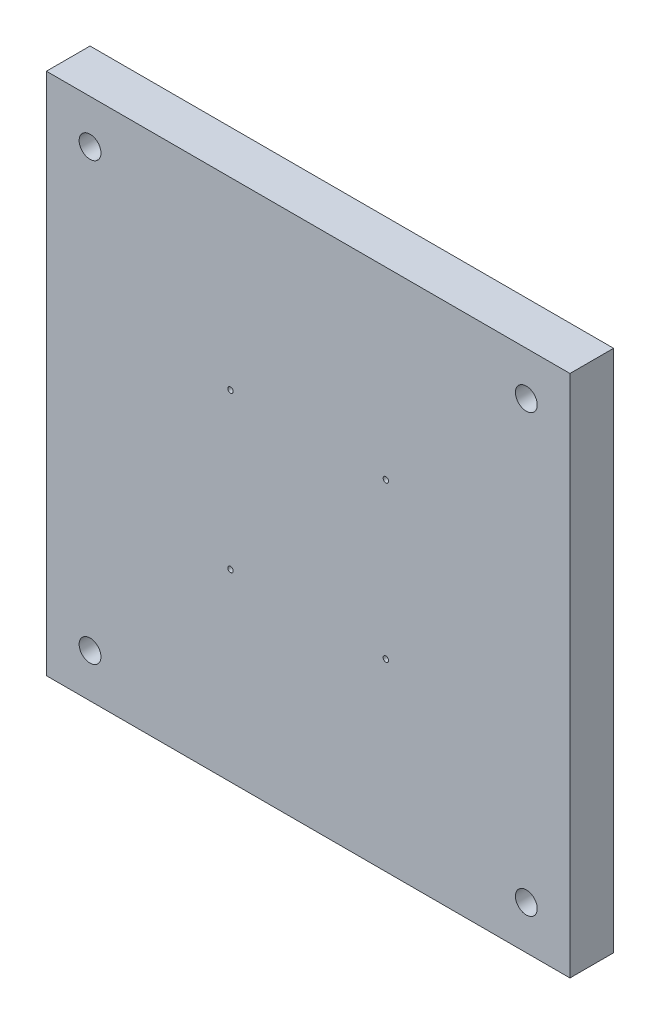
from build123d import *

# Parameters (mm, degrees)
SKETCH1_W           = 76.2
SKETCH1_H           = 76.2
BOSS_EXTRUDE1_DEPTH = 6.35
SKETCH3_R           = 0.396875
CUT_EXTRUDE2_DEPTH  = 108.95
SKETCH4_R           = 1.5875
CUT_EXTRUDE3_DEPTH  = 108.95


with BuildPart() as part:
    # Sketch1 → Boss-Extrude1 (new body)
    with BuildSketch(Plane.XY):
        with Locations((38.1, 38.1)):
            Rectangle(SKETCH1_W, SKETCH1_H)
    extrude(amount=BOSS_EXTRUDE1_DEPTH)

    # Sketch3 → Cut-Extrude2 (cut, through all)
    with BuildSketch(Plane.XY.offset(6.35)):
        with Locations((49.403, 49.403)):
            Circle(SKETCH3_R)
        with Locations((26.797, 49.403)):
            Circle(SKETCH3_R)
        with Locations((26.797, 26.797)):
            Circle(SKETCH3_R)
        with Locations((49.403, 26.797)):
            Circle(SKETCH3_R)
    extrude(amount=-CUT_EXTRUDE2_DEPTH, mode=Mode.SUBTRACT)

    # Sketch4 → Cut-Extrude3 (cut, through all)
    with BuildSketch(Plane(origin=(0, 0, 0), x_dir=(-1, 0, 0), z_dir=(0, 0, -1))):
        with Locations((-6.35, 69.85)):
            Circle(SKETCH4_R)
        with Locations((-6.35, 6.35)):
            Circle(SKETCH4_R)
        with Locations((-69.85, 69.85)):
            Circle(SKETCH4_R)
        with Locations((-69.85, 6.35)):
            Circle(SKETCH4_R)
    extrude(amount=-CUT_EXTRUDE3_DEPTH, mode=Mode.SUBTRACT)


solid = part.part
